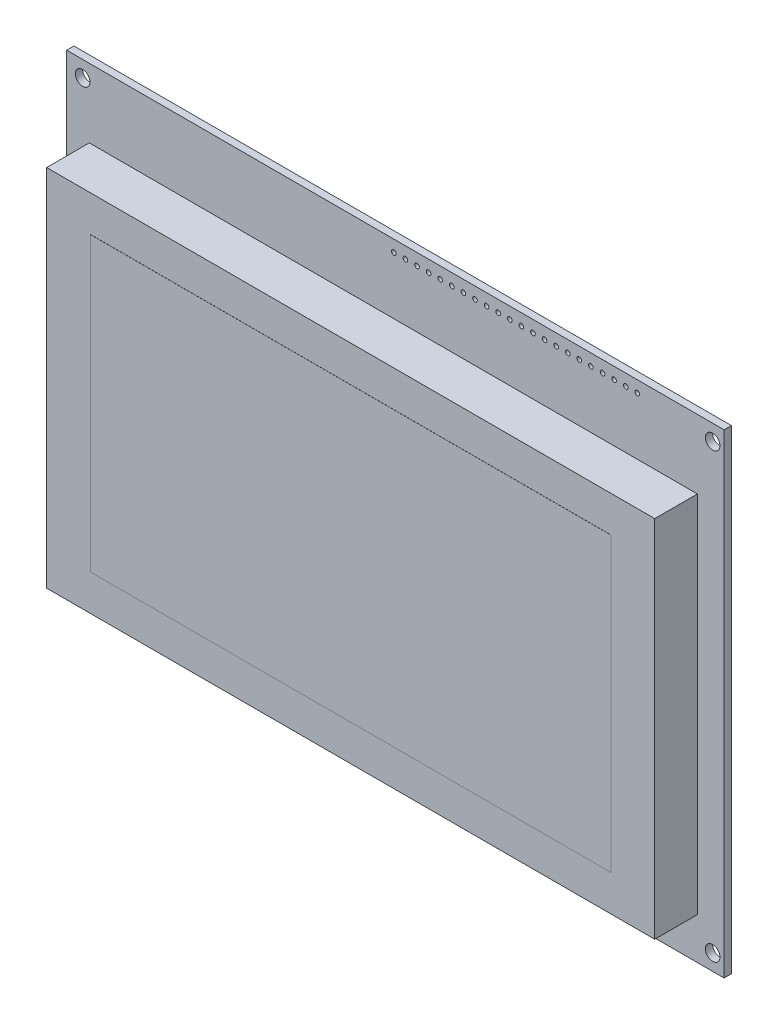
from build123d import *

# Parameters (mm, degrees)
SKETCH1_W           = 144
SKETCH1_H           = 104
SKETCH1_R           = 1.5999968
SKETCH1_R_2         = 0.508
BOSS_EXTRUDE1_DEPTH = 1.6
SKETCH2_W           = 133.200000046
SKETCH2_H           = 79.8
BOSS_EXTRUDE2_DEPTH = 9.3472
SKETCH3_W           = 114
SKETCH3_H           = 64
BOSS_EXTRUDE3_DEPTH = 0.0254


with BuildPart() as part:
    # Sketch1 → Boss-Extrude1 (new body)
    with BuildSketch(Plane.XY):
        Rectangle(SKETCH1_W, SKETCH1_H)
        with Locations((-68.5, 48.5)):
            Circle(SKETCH1_R, mode=Mode.SUBTRACT)
        with Locations((69.5, 48.5)):
            Circle(SKETCH1_R, mode=Mode.SUBTRACT)
        with Locations((69.5, -48.5)):
            Circle(SKETCH1_R, mode=Mode.SUBTRACT)
        with Locations((-68.5, -48.5)):
            Circle(SKETCH1_R, mode=Mode.SUBTRACT)
        with Locations((53, 49.46)):
            Circle(SKETCH1_R_2, mode=Mode.SUBTRACT)
        with Locations((50.46, 49.46)):
            Circle(SKETCH1_R_2, mode=Mode.SUBTRACT)
        with Locations((47.92, 49.46)):
            Circle(SKETCH1_R_2, mode=Mode.SUBTRACT)
        with Locations((45.38, 49.46)):
            Circle(SKETCH1_R_2, mode=Mode.SUBTRACT)
        with Locations((42.84, 49.46)):
            Circle(SKETCH1_R_2, mode=Mode.SUBTRACT)
        with Locations((40.3, 49.46)):
            Circle(SKETCH1_R_2, mode=Mode.SUBTRACT)
        with Locations((37.76, 49.46)):
            Circle(SKETCH1_R_2, mode=Mode.SUBTRACT)
        with Locations((35.22, 49.46)):
            Circle(SKETCH1_R_2, mode=Mode.SUBTRACT)
        with Locations((32.68, 49.46)):
            Circle(SKETCH1_R_2, mode=Mode.SUBTRACT)
        with Locations((30.14, 49.46)):
            Circle(SKETCH1_R_2, mode=Mode.SUBTRACT)
        with Locations((27.6, 49.46)):
            Circle(SKETCH1_R_2, mode=Mode.SUBTRACT)
        with Locations((25.06, 49.46)):
            Circle(SKETCH1_R_2, mode=Mode.SUBTRACT)
        with Locations((22.52, 49.46)):
            Circle(SKETCH1_R_2, mode=Mode.SUBTRACT)
        with Locations((19.98, 49.46)):
            Circle(SKETCH1_R_2, mode=Mode.SUBTRACT)
        with Locations((17.44, 49.46)):
            Circle(SKETCH1_R_2, mode=Mode.SUBTRACT)
        with Locations((14.9, 49.46)):
            Circle(SKETCH1_R_2, mode=Mode.SUBTRACT)
        with Locations((12.36, 49.46)):
            Circle(SKETCH1_R_2, mode=Mode.SUBTRACT)
        with Locations((9.82, 49.46)):
            Circle(SKETCH1_R_2, mode=Mode.SUBTRACT)
        with Locations((7.28, 49.46)):
            Circle(SKETCH1_R_2, mode=Mode.SUBTRACT)
        with Locations((4.74, 49.46)):
            Circle(SKETCH1_R_2, mode=Mode.SUBTRACT)
        with Locations((2.2, 49.46)):
            Circle(SKETCH1_R_2, mode=Mode.SUBTRACT)
        with Locations((-0.34, 49.46)):
            Circle(SKETCH1_R_2, mode=Mode.SUBTRACT)
    extrude(amount=BOSS_EXTRUDE1_DEPTH)

    # Sketch2 → Boss-Extrude2 (add)
    with BuildSketch(Plane.XY.offset(1.6)):
        with Locations((-0.442000023, -3)):
            Rectangle(SKETCH2_W, SKETCH2_H)
    extrude(amount=BOSS_EXTRUDE2_DEPTH)


with BuildPart() as body_2:
    # Sketch3 → Boss-Extrude3 (new body)
    with BuildSketch(Plane.XY.offset(10.9472)):
        with Locations((-0.442000023, -3)):
            Rectangle(SKETCH3_W, SKETCH3_H)
    extrude(amount=BOSS_EXTRUDE3_DEPTH)


solid = Compound([part.part, body_2.part])
